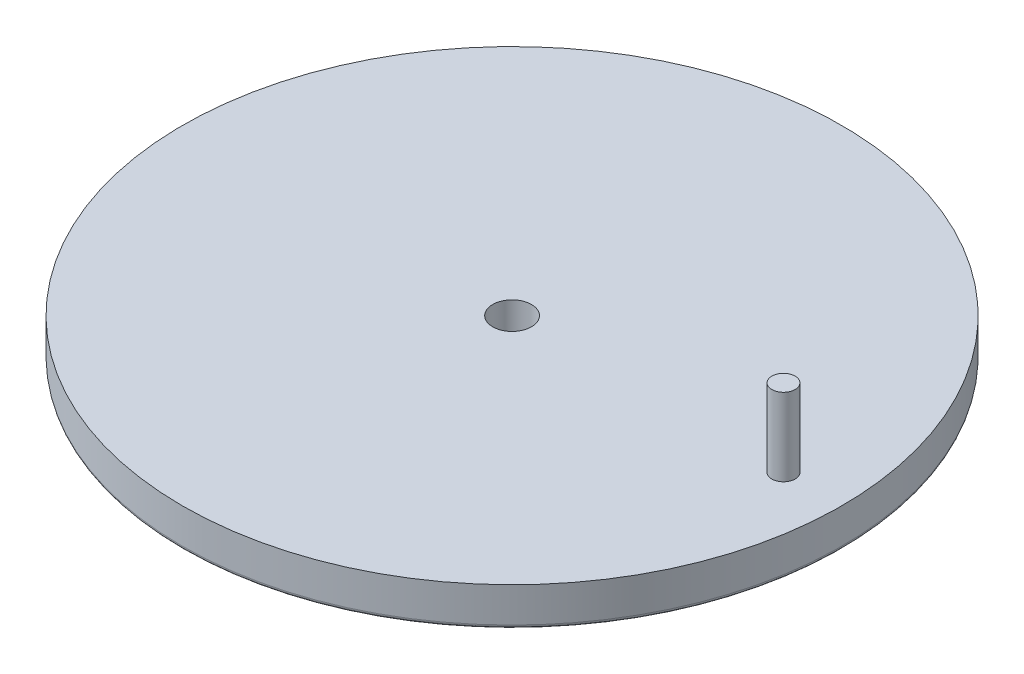
from build123d import *

# Parameters (mm, degrees)
SKETCH1_R           = 42.5
BOSS_EXTRUDE1_DEPTH = 5
SKETCH2_R           = 1.5
BOSS_EXTRUDE2_DEPTH = 10
SKETCH3_R           = 2.5
CUT_EXTRUDE1_DEPTH  = 10
SKETCH4_R           = 5
BOSS_EXTRUDE3_DEPTH = 10
FILLET1_R           = 0.5


with BuildPart() as part:
    # Sketch1 → Boss-Extrude1 (new body)
    with BuildSketch(Plane(origin=(0, 0, 0), x_dir=(1, 0, 0), z_dir=(0, 1, 0))):
        Circle(SKETCH1_R)
    extrude(amount=BOSS_EXTRUDE1_DEPTH)

    # Sketch2 → Boss-Extrude2 (add)
    with BuildSketch(Plane(origin=(0, 5, 0), x_dir=(1, 0, 0), z_dir=(0, 1, 0))):
        with Locations((35, 0)):
            Circle(SKETCH2_R)
    extrude(amount=BOSS_EXTRUDE2_DEPTH)

    # Sketch3 → Cut-Extrude1 (cut)
    with BuildSketch(Plane(origin=(0, 5, 0), x_dir=(1, 0, 0), z_dir=(0, 1, 0))):
        Circle(SKETCH3_R)
    extrude(amount=-CUT_EXTRUDE1_DEPTH, mode=Mode.SUBTRACT)

    # Sketch4 → Boss-Extrude3 (add)
    with BuildSketch(Plane.XZ):
        with Locations((0, -35)):
            Circle(SKETCH4_R)
    extrude(amount=BOSS_EXTRUDE3_DEPTH)

    # Fillet1
    fillet1_edges = [part.edges().sort_by_distance(p)[0] for p in [
        (-42.5, 0, 0),
    ]]
    fillet(fillet1_edges, radius=FILLET1_R)


solid = part.part
